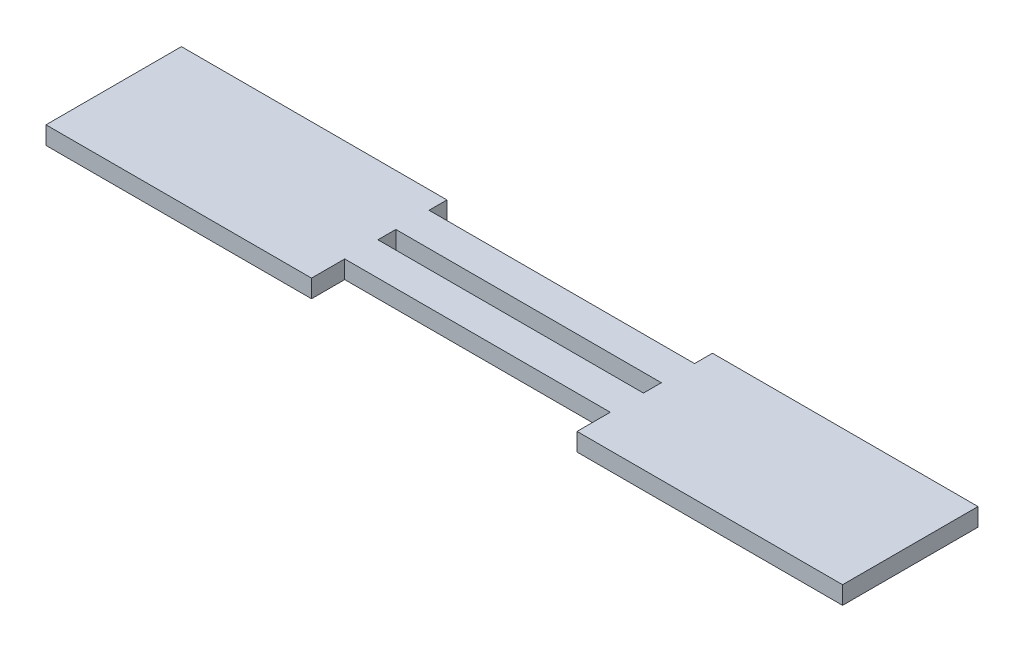
from build123d import *

# Parameters (mm, degrees)
SKETCH1_W           = 40
SKETCH1_H           = 2.7
BOSS_EXTRUDE1_DEPTH = 2.7


with BuildPart() as part:
    # Sketch1 → Boss-Extrude1 (new body)
    with BuildSketch(Plane(origin=(0, 0, 0), x_dir=(1, 0, 0), z_dir=(0, 1, 0))):
        Polygon((-20, 1.790937165), (20, 1.790937165), (20, 4.490937165), (60, 4.490937165), (60, -3.209062835), (60, -5.909062835), (60, -15.909062835), (20, -15.909062835), (20, -10.909062835), (-20, -10.909062835), (-20, -15.909062835), (-60, -15.909062835), (-60, -5.909062835), (-60, -3.209062835), (-60, 4.490937165), (-20, 4.490937165), align=None)
        with Locations((0, -4.559062835)):
            Rectangle(SKETCH1_W, SKETCH1_H, mode=Mode.SUBTRACT)
    extrude(amount=BOSS_EXTRUDE1_DEPTH)


solid = part.part
